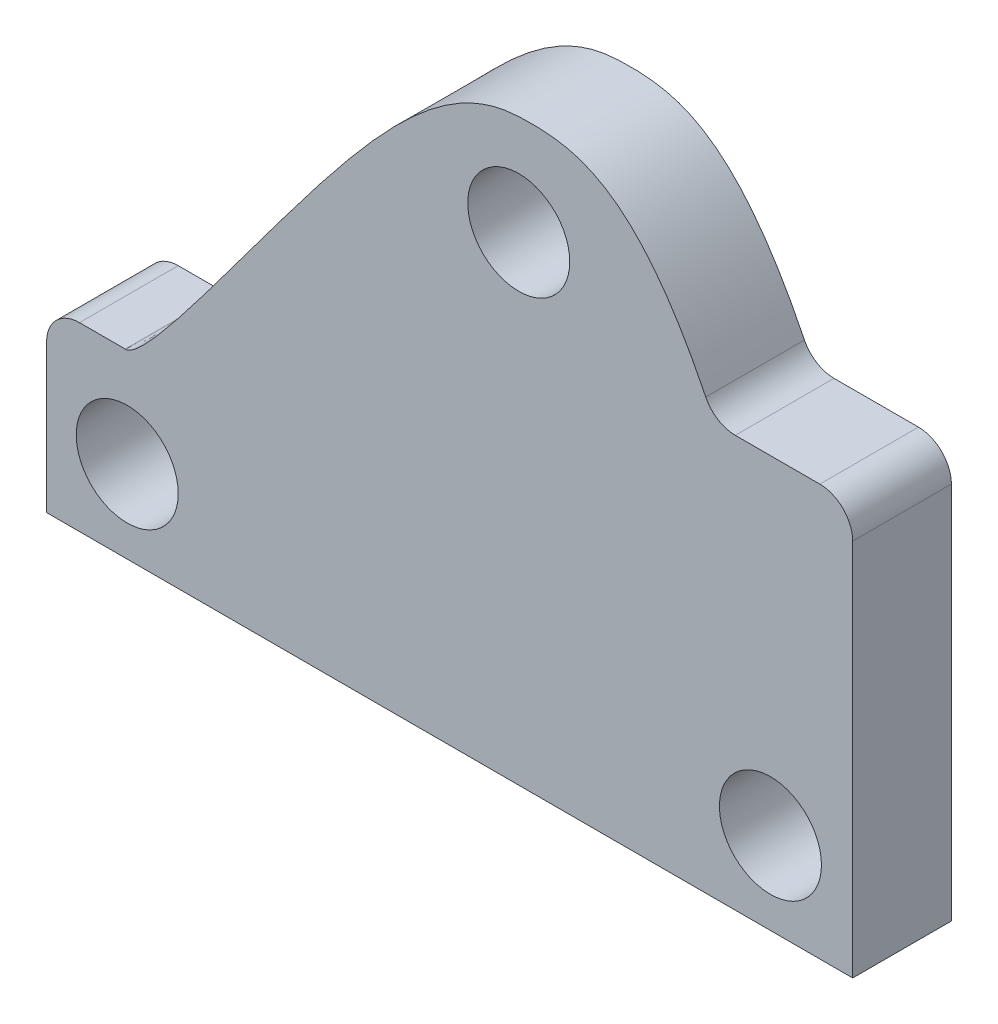
from build123d import *

# Parameters (mm, degrees)
SKETCH1_R           = 3.937
BOSS_EXTRUDE1_DEPTH = 3.81


with BuildPart() as part:
    # Sketch1 → Boss-Extrude1 (new body, symmetric)
    with BuildSketch(Plane.XY):
        with BuildLine():
            Line((31.115, 6.858), (31.115, -22.352))
            Line((31.115, -22.352), (-31.115, -22.352))
            Line((-31.115, -22.352), (-31.115, -10.922))
            ThreePointArc((-31.115, -10.922), (-30.371051224, -9.125948776), (-28.575, -8.382))
            Line((-28.575, -8.382), (-25.049516684, -8.382))
            ThreePointArc((-25.049516684, -8.382), (-25.029149277, -8.382081661), (-25.008783181, -8.382326639))
            add(Edge.make_bspline(
                [(-25.008783181, -8.382326639), (-23.842012802, -8.401040323), (-18.102952542, -0.55711547), (-6.283660278, 15.246737848), (0.033942105, 22.061713275), (9.022065719, 22.599528271), (14.625326979, 21.304399973), (19.772057533, 10.818819135)],
                knots=[0.000772689, 0.000772689, 0.000772689, 0.000772689, 0.263254084, 0.33379531, 0.664808322, 0.734460983, 0.988945287, 0.988945287, 0.988945287, 0.988945287], degree=3))
            ThreePointArc((19.772057533, 10.818819135), (20.708902036, 9.782272814), (22.052196606, 9.398))
            Line((22.052196606, 9.398), (28.575, 9.398))
            ThreePointArc((28.575, 9.398), (30.371051224, 8.654051224), (31.115, 6.858))
        make_face()
        with Locations((5.334, 14.605)):
            Circle(SKETCH1_R, mode=Mode.SUBTRACT)
        with Locations((-24.892, -16.002)):
            Circle(SKETCH1_R, mode=Mode.SUBTRACT)
        with Locations((24.765, -16.002)):
            Circle(SKETCH1_R, mode=Mode.SUBTRACT)
    extrude(amount=BOSS_EXTRUDE1_DEPTH, both=True)


solid = part.part
